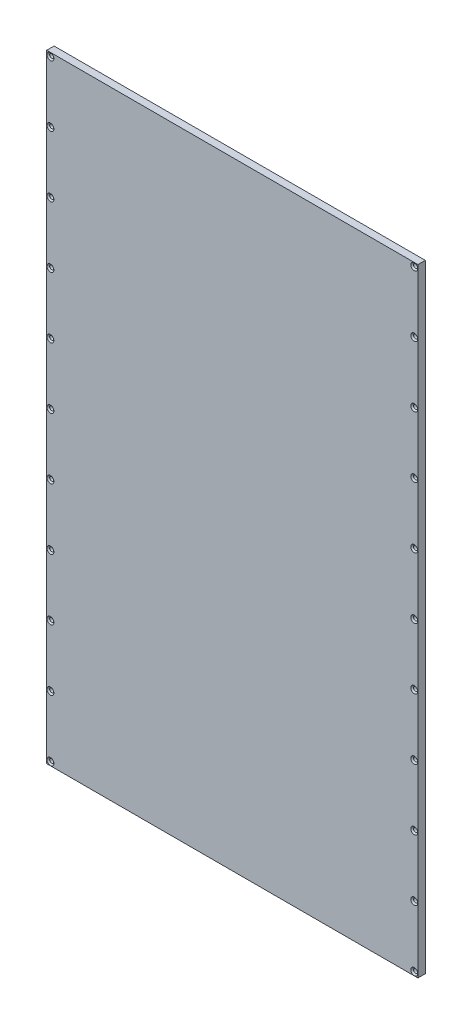
from build123d import *

# Parameters (mm, degrees)
SKETCH1_W                                         = 304
SKETCH1_H                                         = 506
BOSS_EXTRUDE1_DEPTH                               = 6
CSK_FOR_4_FLAT_HEAD_MACHINE_SCREW_100_D           = 3.2639
CSK_FOR_4_FLAT_HEAD_MACHINE_SCREW_100_CSINK_D     = 5.715
CSK_FOR_4_FLAT_HEAD_MACHINE_SCREW_100_CSINK_ANGLE = 100


with BuildPart() as part:
    # Sketch1 → Boss-Extrude1 (new body)
    with BuildSketch(Plane.XY):
        with Locations((152, 253)):
            Rectangle(SKETCH1_W, SKETCH1_H)
    extrude(amount=BOSS_EXTRUDE1_DEPTH)

    # CSK for #4 Flat Head Machine Screw (100)1 (through all)
    with Locations(Plane.XY.offset(6)):
        with Locations((3, 503), (3, 3), (3, 253), (3, 303), (3, 353), (3, 403), (3, 453), (3, 203), (3, 153), (3, 103), (3, 53), (301, 503), (301, 453), (301, 403), (301, 353), (301, 303), (301, 253), (301, 203), (301, 153), (301, 103), (301, 53), (301, 3)):
            CounterSinkHole(CSK_FOR_4_FLAT_HEAD_MACHINE_SCREW_100_D / 2, CSK_FOR_4_FLAT_HEAD_MACHINE_SCREW_100_CSINK_D / 2, counter_sink_angle=CSK_FOR_4_FLAT_HEAD_MACHINE_SCREW_100_CSINK_ANGLE)


solid = part.part
